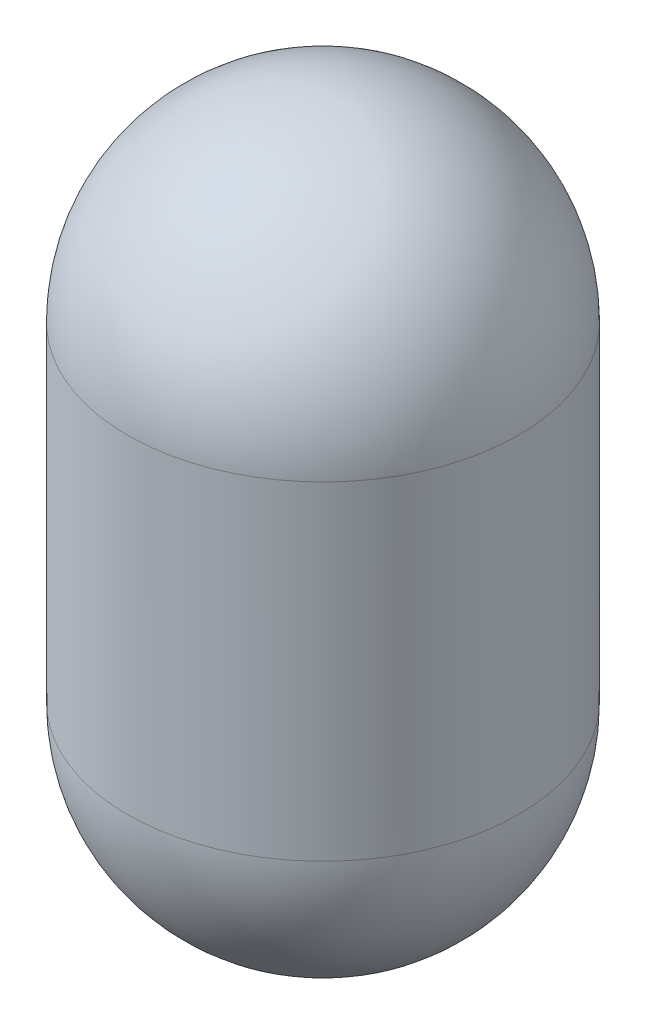
from build123d import *


with BuildPart() as part:
    # Sketch1 → Revolve1 (revolve)
    with BuildSketch(Plane.XY):
        with BuildLine():
            Line((-158.75, -158.75), (-158.75, -425.45))
            ThreePointArc((-158.75, -425.45), (-112.253201513, -537.703201513), (0, -584.2))
            Line((0, -584.2), (0, 0))
            ThreePointArc((0, 0), (-112.253201513, -46.496798487), (-158.75, -158.75))
        make_face()
    revolve(axis=Axis((0, -584.2, 0), (0, 1, 0)))


solid = part.part
